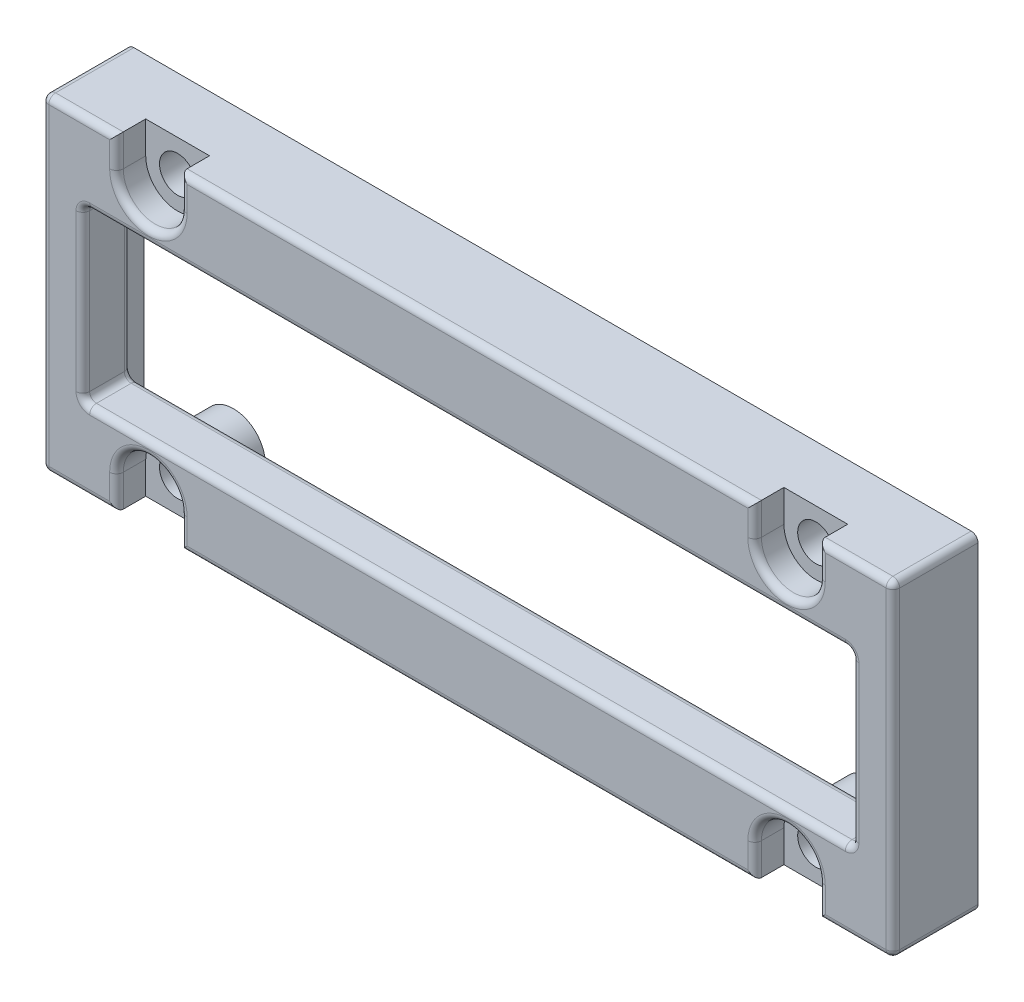
from build123d import *

# Parameters (mm, degrees)
SKETCH1_W                                      = 63.5
SKETCH1_H                                      = 24.384
BOSS_EXTRUDE1_DEPTH                            = 6.35
CBORE_FOR_2_SOCKET_HEAD_CAP_SCREW1_D           = 2.7051
CBORE_FOR_2_SOCKET_HEAD_CAP_SCREW1_CBORE_D     = 4.7625
CBORE_FOR_2_SOCKET_HEAD_CAP_SCREW1_CBORE_DEPTH = 2.1844
SKETCH4_W                                      = 57.404
SKETCH4_H                                      = 12.7
CUT_EXTRUDE1_DEPTH                             = 7.35
SKETCH5_W                                      = 4.7625
SKETCH5_H                                      = 2.3876
CUT_EXTRUDE2_DEPTH                             = 2.1844
SKETCH7_W                                      = 57.404
SKETCH7_H                                      = 12.7
CUT_EXTRUDE3_DEPTH                             = 2.7432
FILLET1_R                                      = 0.508


with BuildPart() as part:
    # Sketch1 → Boss-Extrude1 (new body)
    with BuildSketch(Plane.XY):
        with Locations((137.237805359, -177.626597764)):
            Rectangle(SKETCH1_W, SKETCH1_H)
    extrude(amount=BOSS_EXTRUDE1_DEPTH)

    # CBORE for #2 Socket Head Cap Screw1 (through all)
    with Locations(Plane.XY.offset(6.35)):
        with Locations((161.050305359, -187.430997764), (113.425305359, -187.430997764), (161.050305359, -167.822197764), (113.425305359, -167.822197764)):
            CounterBoreHole(CBORE_FOR_2_SOCKET_HEAD_CAP_SCREW1_D / 2, CBORE_FOR_2_SOCKET_HEAD_CAP_SCREW1_CBORE_D / 2, CBORE_FOR_2_SOCKET_HEAD_CAP_SCREW1_CBORE_DEPTH)

    # Sketch4 → Cut-Extrude1 (cut, through all)
    with BuildSketch(Plane.XY.offset(6.35)):
        with Locations((137.237805359, -177.626597764)):
            Rectangle(SKETCH4_W, SKETCH4_H)
    extrude(amount=-CUT_EXTRUDE1_DEPTH, mode=Mode.SUBTRACT)

    # Sketch5 → Cut-Extrude2 (cut)
    with BuildSketch(Plane.XY.offset(6.35)):
        with Locations((113.425305359, -166.628397764)):
            Rectangle(SKETCH5_W, SKETCH5_H)
        with Locations((161.050305359, -166.628397764)):
            Rectangle(SKETCH5_W, SKETCH5_H)
        with Locations((113.425305359, -188.624797764)):
            Rectangle(SKETCH5_W, SKETCH5_H)
        with Locations((161.050305359, -188.624797764)):
            Rectangle(SKETCH5_W, SKETCH5_H)
    extrude(amount=-CUT_EXTRUDE2_DEPTH, mode=Mode.SUBTRACT)

    # Sketch7 → Cut-Extrude3 (cut)
    with BuildSketch(Plane(origin=(0, 0, 0), x_dir=(-1, 0, 0), z_dir=(0, 0, -1))):
        with BuildLine():
            Line((-163.431555359, -167.822197764), (-163.431555359, -166.704597764))
            Line((-163.431555359, -166.704597764), (-167.717805359, -166.704597764))
            Line((-167.717805359, -166.704597764), (-167.717805359, -188.548597764))
            Line((-167.717805359, -188.548597764), (-163.431555359, -188.548597764))
            Line((-163.431555359, -188.548597764), (-163.431555359, -187.430997764))
            ThreePointArc((-163.431555359, -187.430997764), (-161.050305359, -185.049747764), (-158.669055359, -187.430997764))
            Line((-158.669055359, -187.430997764), (-158.669055359, -188.548597764))
            Line((-158.669055359, -188.548597764), (-115.806555359, -188.548597764))
            Line((-115.806555359, -188.548597764), (-115.806555359, -187.430997764))
            ThreePointArc((-115.806555359, -187.430997764), (-113.425305359, -185.049747764), (-111.044055359, -187.430997764))
            Line((-111.044055359, -187.430997764), (-111.044055359, -188.548597764))
            Line((-111.044055359, -188.548597764), (-106.757805359, -188.548597764))
            Line((-106.757805359, -188.548597764), (-106.757805359, -166.704597764))
            Line((-106.757805359, -166.704597764), (-111.044055359, -166.704597764))
            Line((-111.044055359, -166.704597764), (-111.044055359, -167.822197764))
            ThreePointArc((-111.044055359, -167.822197764), (-113.425305359, -170.203447764), (-115.806555359, -167.822197764))
            Line((-115.806555359, -167.822197764), (-115.806555359, -166.704597764))
            Line((-115.806555359, -166.704597764), (-158.669055359, -166.704597764))
            Line((-158.669055359, -166.704597764), (-158.669055359, -167.822197764))
            ThreePointArc((-158.669055359, -167.822197764), (-161.050305359, -170.203447764), (-163.431555359, -167.822197764))
        make_face()
        with Locations((-137.237805359, -177.626597764)):
            Rectangle(SKETCH7_W, SKETCH7_H, mode=Mode.SUBTRACT)
    extrude(amount=-CUT_EXTRUDE3_DEPTH, mode=Mode.SUBTRACT)

    # Fillet1
    fillet1_edges = [part.edges().sort_by_distance(p)[0] for p in [
        (105.487805359, -177.626597764, 6.35),
        (166.209680359, -189.818597764, 6.35),
        (158.669055359, -188.624797764, 6.35),
        (163.431555359, -188.624797764, 6.35),
        (108.265930359, -189.818597764, 6.35),
        (108.535805359, -171.276597764, 4.5466),
        (165.939805359, -171.276597764, 4.5466),
        (108.535805359, -183.976597764, 4.5466),
        (165.939805359, -183.976597764, 4.5466),
        (163.431555359, -166.704597764, 1.3716),
        (167.717805359, -166.704597764, 1.3716),
        (167.717805359, -188.548597764, 1.3716),
        (163.431555359, -188.548597764, 1.3716),
        (158.669055359, -188.548597764, 1.3716),
        (115.806555359, -188.548597764, 1.3716),
        (111.044055359, -188.548597764, 1.3716),
        (106.757805359, -188.548597764, 1.3716),
        (106.757805359, -166.704597764, 1.3716),
        (111.044055359, -166.704597764, 1.3716),
        (115.806555359, -166.704597764, 1.3716),
        (158.669055359, -166.704597764, 1.3716),
        (137.237805359, -171.276597764, 2.7432),
        (165.939805359, -177.626597764, 2.7432),
        (137.237805359, -183.976597764, 2.7432),
        (108.535805359, -177.626597764, 2.7432),
        (161.050305359, -170.203447764, 2.7432),
        (158.669055359, -167.263397764, 2.7432),
        (137.237805359, -166.704597764, 2.7432),
        (115.806555359, -167.263397764, 2.7432),
        (113.425305359, -170.203447764, 2.7432),
        (111.044055359, -167.263397764, 2.7432),
        (108.900930359, -166.704597764, 2.7432),
        (106.757805359, -177.626597764, 2.7432),
        (108.900930359, -188.548597764, 2.7432),
        (111.044055359, -187.989797764, 2.7432),
        (113.425305359, -185.049747764, 2.7432),
        (115.806555359, -187.989797764, 2.7432),
        (137.237805359, -188.548597764, 2.7432),
        (158.669055359, -187.989797764, 2.7432),
        (161.050305359, -185.049747764, 2.7432),
        (163.431555359, -187.989797764, 2.7432),
        (165.574680359, -188.548597764, 2.7432),
        (167.717805359, -177.626597764, 2.7432),
        (165.574680359, -166.704597764, 2.7432),
        (163.431555359, -167.263397764, 2.7432),
        (113.425305359, -185.049747764, 6.35),
        (161.050305359, -185.049747764, 6.35),
        (168.987805359, -177.626597764, 6.35),
        (165.939805359, -177.626597764, 6.35),
        (137.237805359, -171.276597764, 6.35),
        (108.535805359, -177.626597764, 6.35),
        (137.237805359, -183.976597764, 6.35),
        (113.425305359, -170.203447764, 6.35),
        (108.265930359, -165.434597764, 6.35),
        (115.806555359, -166.628397764, 6.35),
        (111.044055359, -166.628397764, 6.35),
        (166.209680359, -165.434597764, 6.35),
        (168.987805359, -189.818597764, 3.175),
        (105.487805359, -189.818597764, 3.175),
        (161.050305359, -170.203447764, 6.35),
        (105.487805359, -165.434597764, 3.175),
        (168.987805359, -165.434597764, 3.175),
        (137.237805359, -165.434597764, 6.35),
        (163.431555359, -166.628397764, 6.35),
        (158.669055359, -166.628397764, 6.35),
        (137.237805359, -189.818597764, 6.35),
        (115.806555359, -188.624797764, 6.35),
        (111.044055359, -188.624797764, 6.35),
    ]]
    fillet(fillet1_edges, radius=FILLET1_R)


solid = part.part
